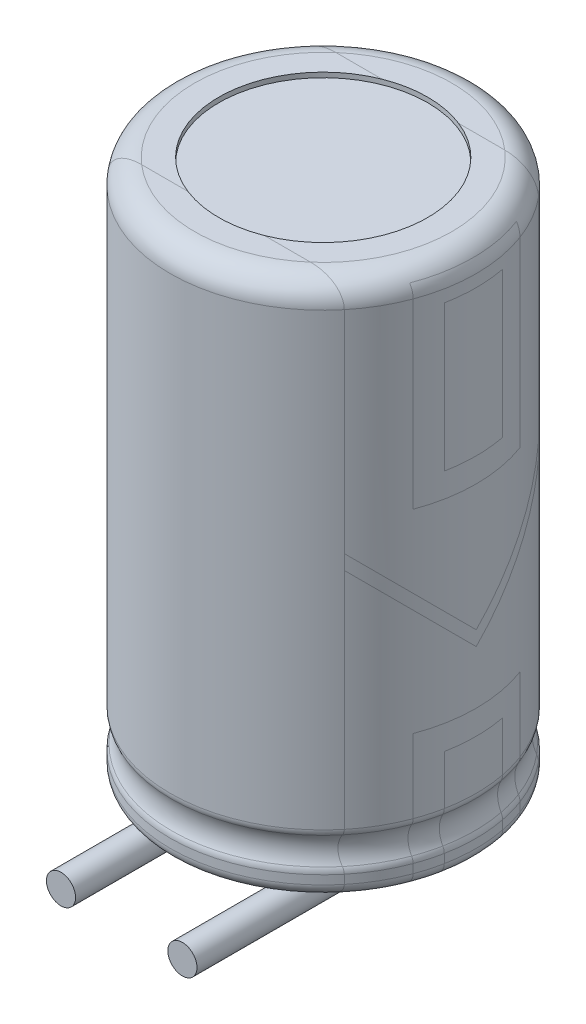
from build123d import *

# Parameters (mm, degrees)
SKETCH4_R = 0.3


with BuildPart() as part:
    # Sketch1 → Revolve1 (revolve)
    with BuildSketch(Plane.XY):
        with BuildLine():
            Line((0, 10.9), (2.15, 10.9))
            Line((2.15, 10.9), (2.15, 11))
            Line((2.15, 11), (2.65, 11))
            ThreePointArc((2.65, 11), (3.003553391, 10.853553391), (3.15, 10.5))
            Line((3.15, 10.5), (3.15, 1.231662479))
            ThreePointArc((3.15, 1.231662479), (3.142535625, 1.171028573), (3.120588235, 1.11401542))
            ThreePointArc((3.120588235, 1.11401542), (3.05, 0.831662479), (3.120588235, 0.549309538))
            ThreePointArc((3.120588235, 0.549309538), (3.142535625, 0.492296385), (3.15, 0.431662479))
            Line((3.15, 0.431662479), (3.15, 0.25))
            ThreePointArc((3.15, 0.25), (3.076776695, 0.073223305), (2.9, 0))
            Line((2.9, 0), (0, 0))
            Line((0, 0), (0, 10.9))
        make_face()
    revolve(axis=Axis((0, 0, 0), (0, 1, 0)))

    # Sweep1: sweep along a path in Sketch5
    with BuildLine(Plane(origin=(-1.25, 0, 0), x_dir=(0, 0, -1), z_dir=(1, 0, 0))) as sweep1_path:
        Line((0, 0), (0, -0.1))
        ThreePointArc((0, -0.1), (-0.146446609, -0.453553391), (-0.5, -0.6))
        Line((-0.5, -0.6), (-4.15, -0.6))
    # Sketch4 → Sweep1 (sweep)
    with BuildSketch(Plane.XZ):
        with Locations((-1.25, 0)):
            Circle(SKETCH4_R)
    sweep1 = sweep(path=sweep1_path.line)

    # Mirror1: Sweep1 across plane
    add(sweep1.mirror(Plane(origin=(0, 0, 0), x_dir=(0, 0, 1), z_dir=(1, 0, 0))))


solid = part.part
